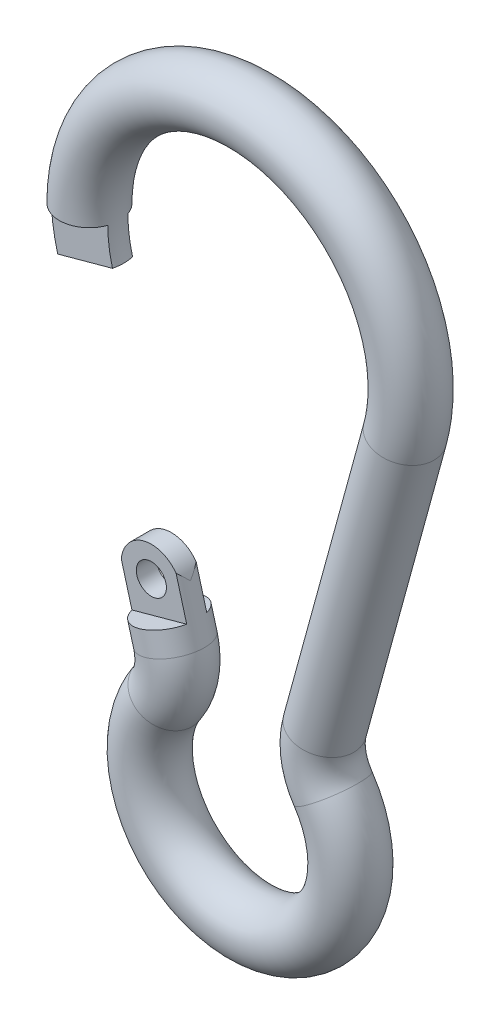
from build123d import *

# Parameters (mm, degrees)
SKETCH2_R               = 3.81
CUT_EXTRUDE2_DEPTH      = 89.396114884
CUT_EXTRUDE2_DEPTH_BACK = 89.396114884
CUT_EXTRUDE3_START      = -23.73
CUT_EXTRUDE3_DEPTH      = 113.126114884
SKETCH7_R               = 1.905
CUT_EXTRUDE4_DEPTH      = 89.396114884
CUT_EXTRUDE4_DEPTH_BACK = 89.396114884
CUT_EXTRUDE5_START      = -23.73
SKETCH7_3_R             = 1.905
CUT_EXTRUDE5_DEPTH      = 113.126114884


with BuildPart() as part:
    # Sweep1: sweep along a path in Sketch1
    with BuildLine(Plane.XY) as sweep1_path:
        Line((15.924188179, 51.521063108), (5.776082855, 14.447725541))
        ThreePointArc((5.776082855, 14.447725541), (5.525966339, 9.551351248), (7.350227861, 5.000625))
        ThreePointArc((7.350227861, 5.000625), (0, -8.89), (-7.350227861, 5.000625))
        ThreePointArc((-7.350227861, 5.000625), (-5.525966339, 9.551351248), (-5.776082855, 14.447725541))
        Line((-5.776082855, 14.447725541), (-15.924188179, 51.521063108))
        ThreePointArc((-15.924188179, 51.521063108), (0, 72.39), (15.924188179, 51.521063108))
    # Sketch2 → Sweep1 (sweep)
    with BuildSketch(Plane(origin=(15.924188179, 51.521063108, 0), x_dir=(-0.9645177576761529, 0.26401798258332, 0), z_dir=(-0.26401798258332, -0.9645177576761529, 0))):
        with Locations((-3.81, 0)):
            Circle(SKETCH2_R)
    sweep(path=sweep1_path.line)

    # Sketch4 → Cut-Extrude2 (cut, two sides)
    with BuildSketch(Plane.XY.offset(25)) as cut_extrude2_sk:
        Polygon((-15.924188179, 51.521063108), (-23.273813493, 49.50924608), (-15.897151059, 22.560619931), (-8.547525746, 24.572436958), align=None)
    extrude(amount=CUT_EXTRUDE2_DEPTH, mode=Mode.SUBTRACT)
    extrude(cut_extrude2_sk.sketch, amount=-CUT_EXTRUDE2_DEPTH_BACK, mode=Mode.SUBTRACT)

    # Sketch5 → Cut-Extrude3 (cut)
    with BuildSketch(Plane.XY.offset(25).offset(CUT_EXTRUDE3_START)):
        with BuildLine():
            Line((-16.51, 55.88), (-24.13, 55.88))
            ThreePointArc((-24.13, 55.88), (-23.914995501, 52.665985344), (-23.273813493, 49.50924608))
            Line((-23.273813493, 49.50924608), (-15.924188179, 51.521063108))
            ThreePointArc((-15.924188179, 51.521063108), (-16.362891658, 53.68093734), (-16.51, 55.88))
        make_face()
    cut_extrude3 = extrude(amount=CUT_EXTRUDE3_DEPTH, mode=Mode.SUBTRACT)

    # Mirror1: Cut-Extrude3 across plane
    add(cut_extrude3.mirror(Plane.XY), mode=Mode.SUBTRACT)

    # Sketch7 → Cut-Extrude4 (cut, two sides)
    with BuildSketch(Plane.XY.offset(25)) as cut_extrude4_sk:
        with BuildLine():
            Line((-15.897151059, 22.560619931), (-14.891242546, 18.885807274))
            ThreePointArc((-14.891242546, 18.885807274), (-14.526199529, 21.778916076), (-12.222338245, 23.566528488))
            Line((-12.222338245, 23.566528488), (-15.897151059, 22.560619931))
        make_face()
        with BuildLine():
            Line((-8.547525746, 24.572436958), (-12.222338245, 23.566528488))
            ThreePointArc((-12.222338245, 23.566528488), (-9.3292296, 23.201485428), (-7.541617232, 20.897624301))
            Line((-7.541617232, 20.897624301), (-8.547525746, 24.572436958))
        make_face()
        with Locations((-11.216429889, 19.891715788)):
            Circle(SKETCH7_R)
    extrude(amount=CUT_EXTRUDE4_DEPTH, mode=Mode.SUBTRACT)
    extrude(cut_extrude4_sk.sketch, amount=-CUT_EXTRUDE4_DEPTH_BACK, mode=Mode.SUBTRACT)

    # Sketch7_3 → Cut-Extrude5 (cut)
    with BuildSketch(Plane.XY.offset(25).offset(CUT_EXTRUDE5_START)):
        with BuildLine():
            Line((-6.535708719, 17.222811645), (-7.541617232, 20.897624301))
            ThreePointArc((-7.541617232, 20.897624301), (-12.222338403, 23.566528444), (-14.891242546, 18.885807274))
            Line((-14.891242546, 18.885807274), (-13.885334032, 15.210994617))
            Line((-13.885334032, 15.210994617), (-6.535708719, 17.222811645))
        make_face()
        with Locations((-11.216429889, 19.891715788)):
            Circle(SKETCH7_3_R, mode=Mode.SUBTRACT)
    cut_extrude5 = extrude(amount=CUT_EXTRUDE5_DEPTH, mode=Mode.SUBTRACT)

    # Mirror2: Cut-Extrude5 across plane
    add(cut_extrude5.mirror(Plane.XY), mode=Mode.SUBTRACT)


solid = part.part
